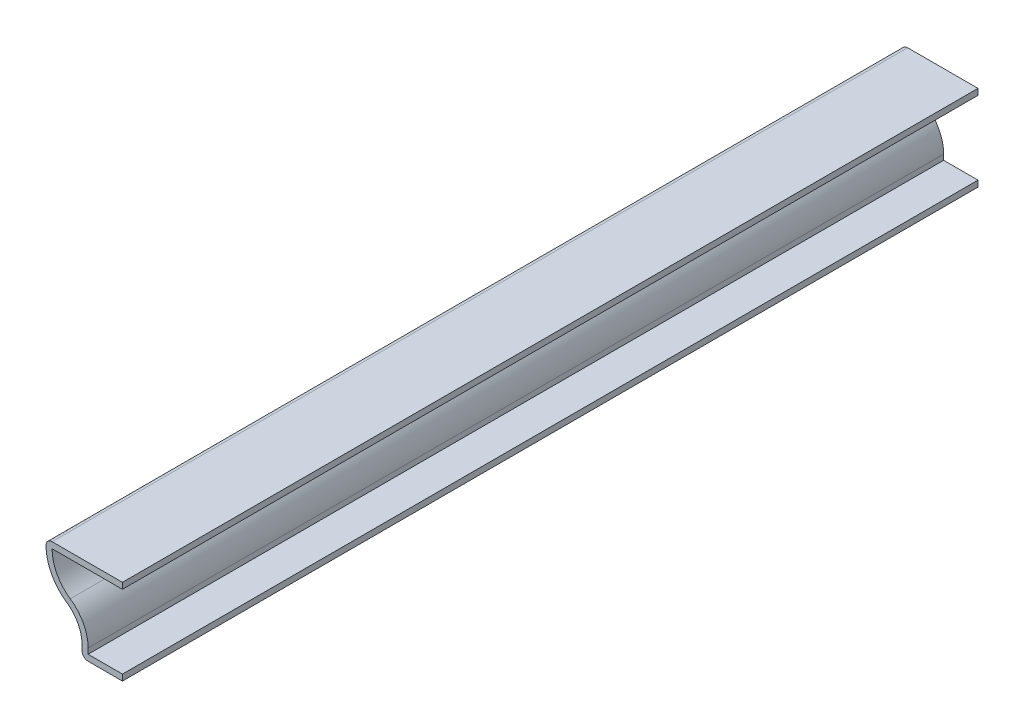
from build123d import *

# Parameters (mm, degrees)
EXTRUDE_THIN1_DEPTH = 142.875
FILLET1_R           = 1.016


with BuildPart() as part:
    # Sketch1 → Extrude-Thin1 (new body)
    with BuildSketch(Plane.XY):
        with BuildLine():
            Line((0, 0), (-6.746875, 0))
            Line((-6.746875, 0), (-6.746875, 1.919148688))
            ThreePointArc((-6.746875, 1.919148688), (-7.41996004, 4.62577026), (-9.28241202, 6.70185225))
            ThreePointArc((-9.28241202, 6.70185225), (-12.064724111, 10.011020322), (-12.7, 14.2875))
            Line((-12.7, 14.2875), (0, 14.2875))
            Line((0, 14.2875), (0, 13.2715))
            Line((0, 13.2715), (-11.749292543, 13.2715))
            ThreePointArc((-11.749292543, 13.2715), (-10.943069803, 10.029502732), (-8.712220727, 7.542767162))
            ThreePointArc((-8.712220727, 7.542767162), (-6.522304662, 5.101659767), (-5.730875, 1.919148688))
            Line((-5.730875, 1.919148688), (-5.730875, 1.016))
            Line((-5.730875, 1.016), (0, 1.016))
            Line((0, 1.016), (0, 0))
        make_face()
    extrude(amount=-EXTRUDE_THIN1_DEPTH)

    # Fillet1
    fillet1_edges = [part.edges().sort_by_distance(p)[0] for p in [
        (-6.746875, 0, -71.4375),
        (-12.7, 14.2875, -71.4375),
    ]]
    fillet(fillet1_edges, radius=FILLET1_R)


solid = part.part
